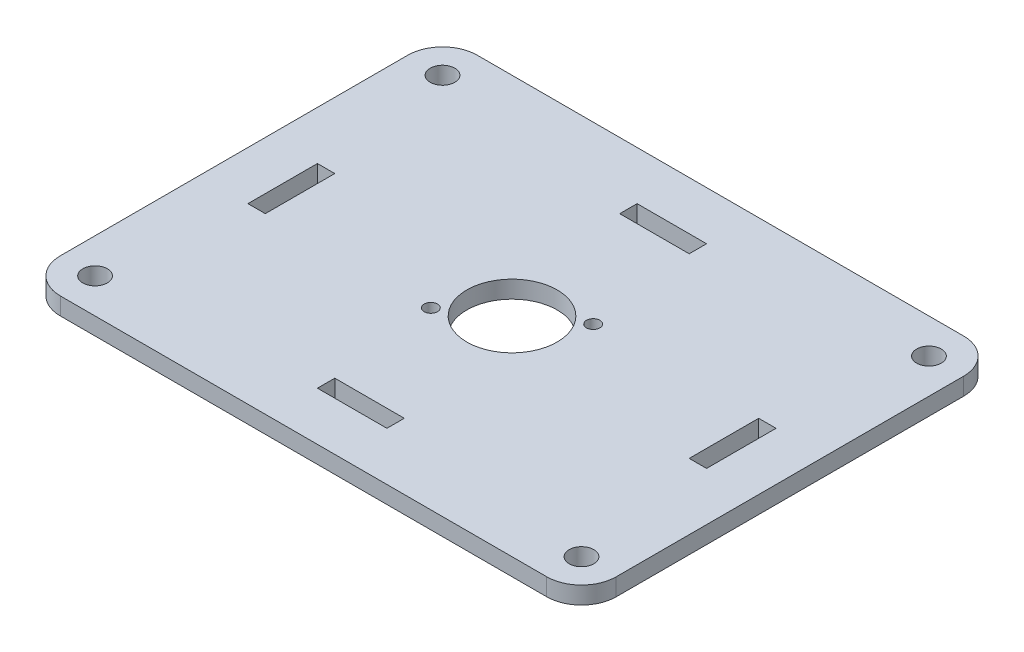
from build123d import *

# Parameters (mm, degrees)
SKETCH1_W           = 101.6
SKETCH1_H           = 76.2
BOSS_EXTRUDE1_DEPTH = 3.175
FILLET1_R           = 6.35
SKETCH2_R           = 2.2479
CUT_EXTRUDE1_DEPTH  = 4.175
SKETCH3_R           = 8.255
SKETCH3_R_2         = 1.2192
CUT_EXTRUDE2_DEPTH  = 4.175


with BuildPart() as part:
    # Sketch1 → Boss-Extrude1 (new body)
    with BuildSketch(Plane(origin=(0, 0, 0), x_dir=(1, 0, 0), z_dir=(0, 1, 0))):
        Rectangle(SKETCH1_W, SKETCH1_H)
    extrude(amount=BOSS_EXTRUDE1_DEPTH)

    # Fillet1
    fillet1_edges = [part.edges().sort_by_distance(p)[0] for p in [
        (50.8, 1.5875, 38.1),
        (-50.8, 1.5875, 38.1),
        (-50.8, 1.5875, -38.1),
        (50.8, 1.5875, -38.1),
    ]]
    fillet(fillet1_edges, radius=FILLET1_R)

    # Sketch2 → Cut-Extrude1 (cut, through all)
    with BuildSketch(Plane(origin=(0, 3.175, 0), x_dir=(1, 0, 0), z_dir=(0, 1, 0))):
        with Locations((-44.45, 31.75)):
            Circle(SKETCH2_R)
        with Locations((44.45, 31.75)):
            Circle(SKETCH2_R)
        with Locations((44.45, -31.75)):
            Circle(SKETCH2_R)
        with Locations((-44.45, -31.75)):
            Circle(SKETCH2_R)
        Polygon((-41.91, 0), (-41.91, 6.35), (-38.735, 6.35), (-38.735, -6.35), (-41.91, -6.35), align=None)
        Polygon((0, 29.21), (6.35, 29.21), (6.35, 26.035), (-6.35, 26.035), (-6.35, 29.21), align=None)
        Polygon((41.91, 0), (41.91, 6.35), (38.735, 6.35), (38.735, -6.35), (41.91, -6.35), align=None)
        Polygon((0, -29.21), (6.35, -29.21), (6.35, -26.035), (-6.35, -26.035), (-6.35, -29.21), align=None)
    extrude(amount=-CUT_EXTRUDE1_DEPTH, mode=Mode.SUBTRACT)

    # Sketch3 → Cut-Extrude2 (cut, through all)
    with BuildSketch(Plane(origin=(0, 3.175, 0), x_dir=(1, 0, 0), z_dir=(0, 1, 0))):
        Circle(SKETCH3_R)
        with Locations((-8.6995, -6.1341)):
            Circle(SKETCH3_R_2)
        with Locations((8.6995, 6.1341)):
            Circle(SKETCH3_R_2)
    extrude(amount=-CUT_EXTRUDE2_DEPTH, mode=Mode.SUBTRACT)


solid = part.part
